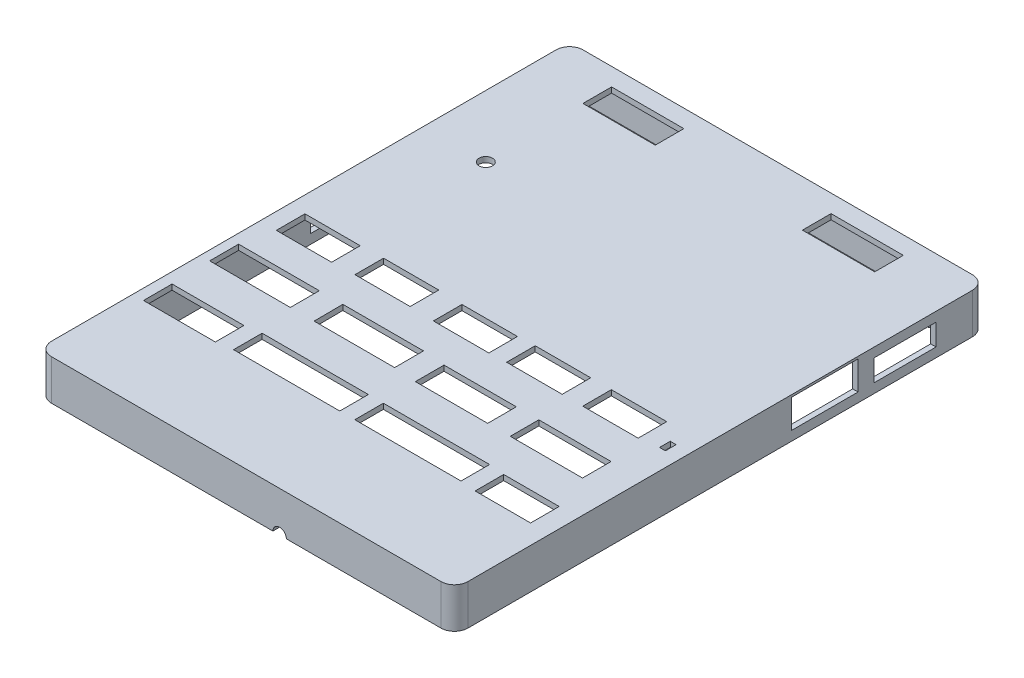
from build123d import *

# Parameters (mm, degrees)
SKETCH3_W            = 62.732633811
SKETCH3_H            = 79.574938689
SKETCH3_W_2          = 61.132633811
SKETCH3_H_2          = 77.974938689
BOSS_EXTRUDE8_DEPTH  = 6
SKETCH2_R            = 2.2
SKETCH2_R_2          = 1.409397898
BOSS_EXTRUDE9_DEPTH  = 4.6
SKETCH4_W            = 61.132633811
SKETCH4_H            = 77.974938689
BOSS_EXTRUDE11_DEPTH = 0.8
CUT_EXTRUDE2_DEPTH   = 4
SKETCH8_W            = 6.35
SKETCH8_H            = 1.7
SKETCH8_W_2          = 9.791634441
SKETCH8_H_2          = 4.4
SKETCH8_W_3          = 7.621
CUT_EXTRUDE3_DEPTH   = 1
SKETCH10_R           = 1
CUT_EXTRUDE4_DEPTH   = 10
SKETCH11_W           = 62.732633811
SKETCH11_H           = 0.53
CUT_EXTRUDE5_DEPTH   = 10
SKETCH12_W           = 61.132633811
SKETCH12_H           = 0.529997491
BOSS_EXTRUDE12_DEPTH = 6
BOSS_EXTRUDE14_DEPTH = 6
SKETCH16_W           = 0.807943928
SKETCH16_H           = 79.044938689
CUT_EXTRUDE6_DEPTH   = 10
CUT_EXTRUDE7_DEPTH   = 10
SKETCH20_W           = 9.7916
SKETCH20_H           = 4.3
SKETCH20_W_2         = 7.621
CUT_EXTRUDE9_DEPTH   = 4
FILLET1_R            = 2


with BuildPart() as part:
    # Sketch3 → Boss-Extrude8 (new body)
    with BuildSketch(Plane(origin=(0, 0, 0), x_dir=(1, 0, 0), z_dir=(0, 1, 0))):
        with Locations((27.16866126, -36.269344827)):
            Rectangle(SKETCH3_W, SKETCH3_H)
        with Locations((27.16866126, -36.269344827)):
            Rectangle(SKETCH3_W_2, SKETCH3_H_2, mode=Mode.SUBTRACT)
    extrude(amount=-BOSS_EXTRUDE8_DEPTH)

    # Sketch2 → Boss-Extrude9 (add)
    with BuildSketch(Plane(origin=(0, 0, 0), x_dir=(1, 0, 0), z_dir=(0, 1, 0))):
        Circle(SKETCH2_R)
        Circle(SKETCH2_R_2, mode=Mode.SUBTRACT)
        with Locations((54.706786111, 0.127852524)):
            Circle(SKETCH2_R)
        with Locations((54.706786111, 0.127852524)):
            Circle(SKETCH2_R_2, mode=Mode.SUBTRACT)
        with Locations((52.730413392, -72.978026956)):
            Circle(SKETCH2_R)
        with Locations((52.730413392, -72.978026956)):
            Circle(SKETCH2_R_2, mode=Mode.SUBTRACT)
        with Locations((-1.28124336, -73.51791918)):
            Circle(SKETCH2_R)
        with Locations((-1.28124336, -73.51791918)):
            Circle(SKETCH2_R_2, mode=Mode.SUBTRACT)
    extrude(amount=-BOSS_EXTRUDE9_DEPTH)

    # Sketch4 → Boss-Extrude11 (add)
    with BuildSketch(Plane(origin=(0, 0, 0), x_dir=(1, 0, 0), z_dir=(0, 1, 0))):
        with Locations((27.16866126, -36.269344827)):
            Rectangle(SKETCH4_W, SKETCH4_H)
    extrude(amount=-BOSS_EXTRUDE11_DEPTH)

    # Sketch7 → Cut-Extrude2 (cut)
    with BuildSketch(Plane(origin=(58.534978165, 0, 0), x_dir=(0, 0, -1), z_dir=(1, 0, 0))):
        Polygon((-3.898875483, -4.6), (-3.898875483, -2.1), (-3.898875483, -1.5), (-3.898875483, -1.4), (-13.125875483, -1.4), (-13.125875483, -1.5), (-13.125875483, -2.1), (-13.125875483, -4.6), align=None)
        Polygon((-15.492875483, -4.6), (-15.492875483, -0.6), (-15.492875483, -0.33), (-25.398875483, -0.33), (-25.398875483, -0.6), (-25.398875483, -4.6), align=None)
    extrude(amount=-CUT_EXTRUDE2_DEPTH, mode=Mode.SUBTRACT)

    # Sketch8 → Cut-Extrude3 (cut)
    with BuildSketch(Plane.ZY.offset(4.197655646)):
        with Locations((8.256875483, -3.75)):
            Rectangle(SKETCH8_W, SKETCH8_H)
        with Locations((19.363058263, -2.4)):
            Rectangle(SKETCH8_W_2, SKETCH8_H_2)
        with Locations((32.006375483, -2.4)):
            Rectangle(SKETCH8_W_3, SKETCH8_H_2)
    extrude(amount=-CUT_EXTRUDE3_DEPTH, mode=Mode.SUBTRACT)

    # Sketch10 → Cut-Extrude4 (cut)
    with BuildSketch(Plane(origin=(0, 0, 0), x_dir=(1, 0, 0), z_dir=(0, 1, 0))):
        with Locations((5.825978165, -18.159875483)):
            Circle(SKETCH10_R)
        Polygon((44.485978165, -38.144875483), (44.485978165, -41.994875483), (44.485978165, -42.394875483), (52.725978165, -42.394875483), (52.725978165, -38.144875483), (52.365978165, -38.144875483), align=None)
        Polygon((33.166978165, -38.144875483), (33.166978165, -41.994875483), (33.166978165, -42.394875483), (41.426978165, -42.394875483), (41.426978165, -38.144875483), (41.046978165, -38.144875483), align=None)
        Polygon((22.401978165, -41.994875483), (22.401978165, -38.274875483), (30.291978165, -38.274875483), (30.651978165, -38.274875483), (30.651978165, -42.524875483), (22.401978165, -42.524875483), align=None)
        Polygon((10.606978165, -38.144875483), (10.606978165, -41.994875483), (10.606978165, -42.394875483), (18.816978165, -42.394875483), (18.816978165, -38.144875483), (18.456978165, -38.144875483), align=None)
        Polygon((-0.950021835, -41.994875483), (-0.950021835, -38.274875483), (6.899978165, -38.274875483), (7.269978165, -38.274875483), (7.269978165, -42.534875483), (-0.950021835, -42.534875483), align=None)
        Polygon((25.154978165, -47.115875483), (13.774978165, -47.115875483), (13.524978165, -47.115875483), (13.552673933, -51.415875483), (13.774978165, -51.415875483), (25.524978165, -51.415875483), (25.524978165, -47.115875483), align=None)
        Polygon((-1.756021835, -47.115875483), (9.663978165, -47.115875483), (10.023978165, -47.115875483), (10.023978165, -51.425875483), (-1.756021835, -51.425875483), (-1.976021835, -51.425875483), (-1.976021835, -47.115875483), align=None)
        Polygon((47.402978165, -57.067875483), (55.012978165, -57.067875483), (55.652978165, -57.067875483), (55.652978165, -61.317875483), (47.402978165, -61.317875483), (47.402978165, -60.917875483), align=None)
        Polygon((38.146978165, 0.382124517), (38.146978165, -3.385875483), (48.535978165, -3.385875483), (48.895978165, -3.385875483), (48.895978165, 0.872124517), (38.146978165, 0.872124517), align=None)
        Polygon((15.896978165, -3.385875483), (5.507978165, -3.385875483), (5.507978165, 0.382124517), (5.507978165, 0.872124517), (16.256978165, 0.872124517), (16.256978165, -3.385875483), align=None)
        Polygon((53.361978165, -47.415875483), (43.784978165, -47.415875483), (42.974978165, -47.415875483), (42.974978165, -51.665875483), (43.784978165, -51.665875483), (53.721978165, -51.665875483), (53.721978165, -47.415875483), align=None)
        Polygon((29.687978165, -47.415875483), (39.264978165, -47.415875483), (39.624978165, -47.415875483), (39.624978165, -51.675875483), (29.687978165, -51.675875483), (28.876408648, -51.675875483), (28.876408648, -47.415875483), align=None)
        Polygon((-1.793021835, -57.197875483), (-1.793021835, -60.917875483), (-1.793021835, -61.447875483), (8.896978165, -61.447875483), (8.896978165, -57.197875483), (8.706978165, -57.197875483), align=None)
        Polygon((29.275978165, -56.837875483), (29.275978165, -60.917875483), (29.275978165, -61.087875483), (45.073978165, -61.087875483), (45.073978165, -56.837875483), (44.753978165, -56.837875483), align=None)
        Polygon((11.239978165, -56.837875483), (11.239978165, -60.917875483), (11.239978165, -61.087875483), (27.039978165, -61.087875483), (27.039978165, -56.837875483), (26.719978165, -56.837875483), align=None)
        Polygon((56.285232814, -41.994875483), (55.509188938, -41.994875483), (55.509188938, -40.403875483), (56.385232814, -40.403875483), (56.385232814, -41.994875483), align=None)
    extrude(amount=-CUT_EXTRUDE4_DEPTH, mode=Mode.SUBTRACT)

    # Sketch11 → Cut-Extrude5 (cut)
    with BuildSketch(Plane(origin=(0, 0, 0), x_dir=(1, 0, 0), z_dir=(0, 1, 0))):
        with Locations((27.16866126, -75.791814172)):
            Rectangle(SKETCH11_W, SKETCH11_H)
    extrude(amount=-CUT_EXTRUDE5_DEPTH, mode=Mode.SUBTRACT)

    # Sketch12 → Boss-Extrude12 (add)
    with BuildSketch(Plane.XZ.offset(6)):
        with Locations((27.16866126, 74.991815427)):
            Rectangle(SKETCH12_W, SKETCH12_H)
    extrude(amount=-BOSS_EXTRUDE12_DEPTH)

    # Sketch15 → Boss-Extrude14 (add)
    with BuildSketch(Plane.XZ.offset(6)):
        Polygon((-3.397655646, 74.726816681), (-2.587655646, 74.726816681), (-2.587655646, -2.718124517), (-2.587655646, -3.518124517), (-3.397655646, -3.518124517), align=None)
    extrude(amount=-BOSS_EXTRUDE14_DEPTH)

    # Sketch16 → Cut-Extrude6 (cut)
    with BuildSketch(Plane.XZ.offset(6)):
        with Locations((-3.793683682, 36.004344827)):
            Rectangle(SKETCH16_W, SKETCH16_H)
    extrude(amount=-CUT_EXTRUDE6_DEPTH, mode=Mode.SUBTRACT)

    # Sketch17 → Cut-Extrude7 (cut)
    with BuildSketch(Plane.XY.offset(75.526814172)):
        with BuildLine():
            Line((31.534978165, -6), (33.534978165, -6))
            ThreePointArc((33.534978165, -6), (32.534978165, -5), (31.534978165, -6))
        make_face()
    extrude(amount=-CUT_EXTRUDE7_DEPTH, mode=Mode.SUBTRACT)

    # Sketch20 → Cut-Extrude9 (cut)
    with BuildSketch(Plane.ZY.offset(3.389711718)):
        Polygon((5.081875483, -4.6), (5.081875483, -2.9), (5.081875483, -2.75), (11.431875483, -2.75), (11.431875483, -2.9), (11.431875483, -4.6), align=None)
        with Locations((19.367675483, -2.45)):
            Rectangle(SKETCH20_W, SKETCH20_H)
        with Locations((32.002375483, -2.45)):
            Rectangle(SKETCH20_W_2, SKETCH20_H)
    extrude(amount=-CUT_EXTRUDE9_DEPTH, mode=Mode.SUBTRACT)

    # Fillet1
    fillet1_edges = [part.edges().sort_by_distance(p)[0] for p in [
        (58.534978165, -3, 75.526814172),
        (-3.389711718, -3, 75.526814172),
        (-3.389711718, -3, -3.518124517),
        (58.534978165, -3, -3.518124517),
    ]]
    fillet(fillet1_edges, radius=FILLET1_R)


solid = part.part
